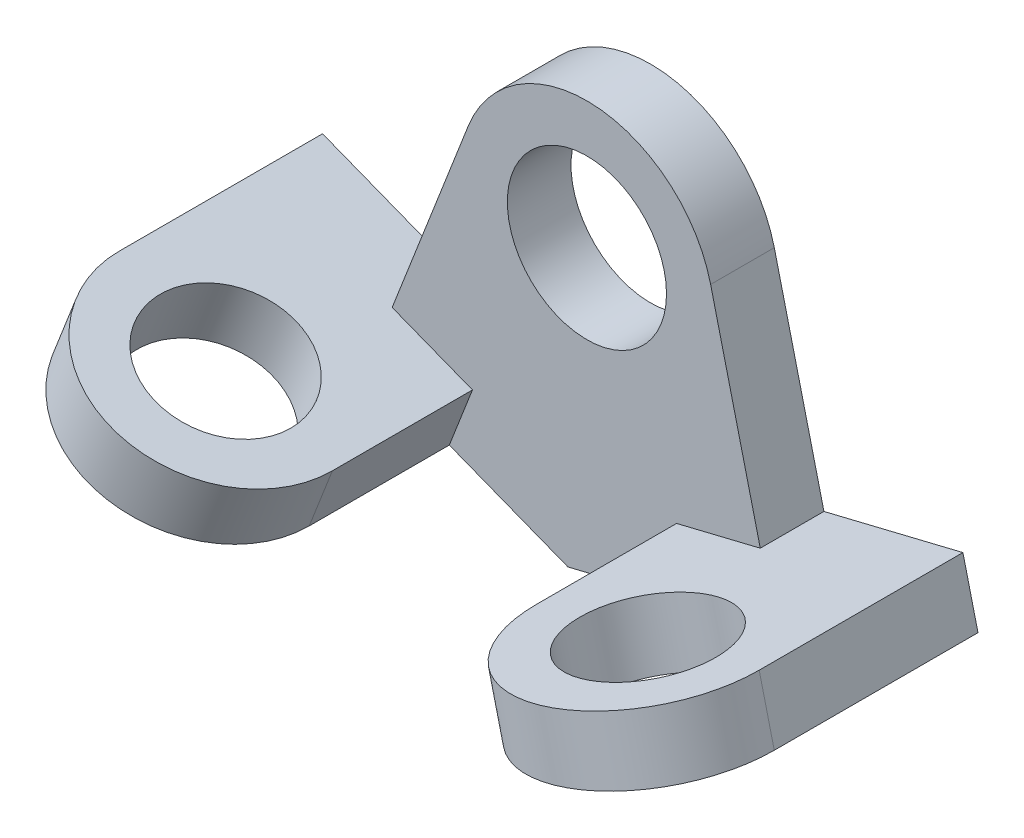
from build123d import *

# Parameters (mm, degrees)
SKETCH1_R           = 12.5
BOSS_EXTRUDE1_DEPTH = 10
BOSS_EXTRUDE2_DEPTH = 64
SKETCH3_R           = 11
CUT_EXTRUDE1_DEPTH  = 64
BOSS_EXTRUDE3_DEPTH = 10
BOSS_EXTRUDE4_DEPTH = 10


with BuildPart() as part:
    # Sketch1 → Boss-Extrude1 (new body)
    with BuildSketch(Plane.XY):
        with BuildLine():
            Line((-18.634160035, 7.264164081), (-34.222061974, -32.722193067))
            Line((-34.222061974, -32.722193067), (-2.980251959, -44.901203751))
            Line((-2.980251959, -44.901203751), (29.597134129, -36.958099196))
            Line((29.597134129, -36.958099196), (19.430763633, 4.73766025))
            ThreePointArc((19.430763633, 4.73766025), (1.324556426, 19.956090556), (-18.634160035, 7.264164081))
        make_face()
        Circle(SKETCH1_R, mode=Mode.SUBTRACT)
    extrude(amount=BOSS_EXTRUDE1_DEPTH)

    # Sketch2 → Boss-Extrude2 (add)
    with BuildSketch(Plane.XY.offset(10)):
        Polygon((27.228304004, -27.24271738), (29.597134129, -36.958099196), (51.425886213, -31.635755051), (49.057056089, -21.920373235), align=None)
        Polygon((16.450511674, -40.163543501), (29.597134129, -36.958099196), (27.228304004, -27.24271738), (14.081681549, -30.448161684), align=None)
    boss_extrude2 = extrude(amount=BOSS_EXTRUDE2_DEPTH)

    # Sketch3 → Cut-Extrude1 (cut)
    with BuildSketch(Plane(origin=(7.797540371, -31.98037763, 0), x_dir=(0.971538182, 0.236883012, 0), z_dir=(-0.236883012, 0.971538182, 0))):
        with Locations((24.468239022, -32)):
            Circle(SKETCH3_R)
        with BuildLine():
            ThreePointArc((42.468239022, -32), (24.468239022, -50), (6.468239022, -32))
            Line((6.468239022, -32), (6.468239022, -74))
            Line((6.468239022, -74), (42.468239022, -74))
            Line((42.468239022, -74), (42.468239022, -32))
        make_face()
    cut_extrude1 = extrude(amount=-CUT_EXTRUDE1_DEPTH, mode=Mode.SUBTRACT)

    # Mirror1: Boss-Extrude2, Cut-Extrude1 across plane
    add(boss_extrude2.mirror(Plane(origin=(0, 0, 0), x_dir=(0, 0, 1), z_dir=(-0.997804528, 0.066227821, 0))))
    add(cut_extrude1.mirror(Plane(origin=(0, 0, 0), x_dir=(0, 0, 1), z_dir=(-0.997804528, 0.066227821, 0))), mode=Mode.SUBTRACT)

    # Sketch5 → Boss-Extrude3 (add)
    with BuildSketch(Plane(origin=(0, 0, 10), x_dir=(-1, 0, 0), z_dir=(0, 0, -1))):
        Polygon((-49.057056089, -21.920373235), (-51.425886213, -31.635755051), (-29.597134129, -36.958099196), (-27.228304004, -27.24271738), align=None)
    extrude(amount=BOSS_EXTRUDE3_DEPTH)

    # Sketch6 → Boss-Extrude4 (add)
    with BuildSketch(Plane(origin=(0, 0, 10), x_dir=(-1, 0, 0), z_dir=(0, 0, -1))):
        Polygon((30.589979933, -23.405113049), (34.222061974, -32.722193067), (55.155900056, -24.561544323), (51.523818015, -15.244464306), align=None)
    extrude(amount=BOSS_EXTRUDE4_DEPTH)


solid = part.part
